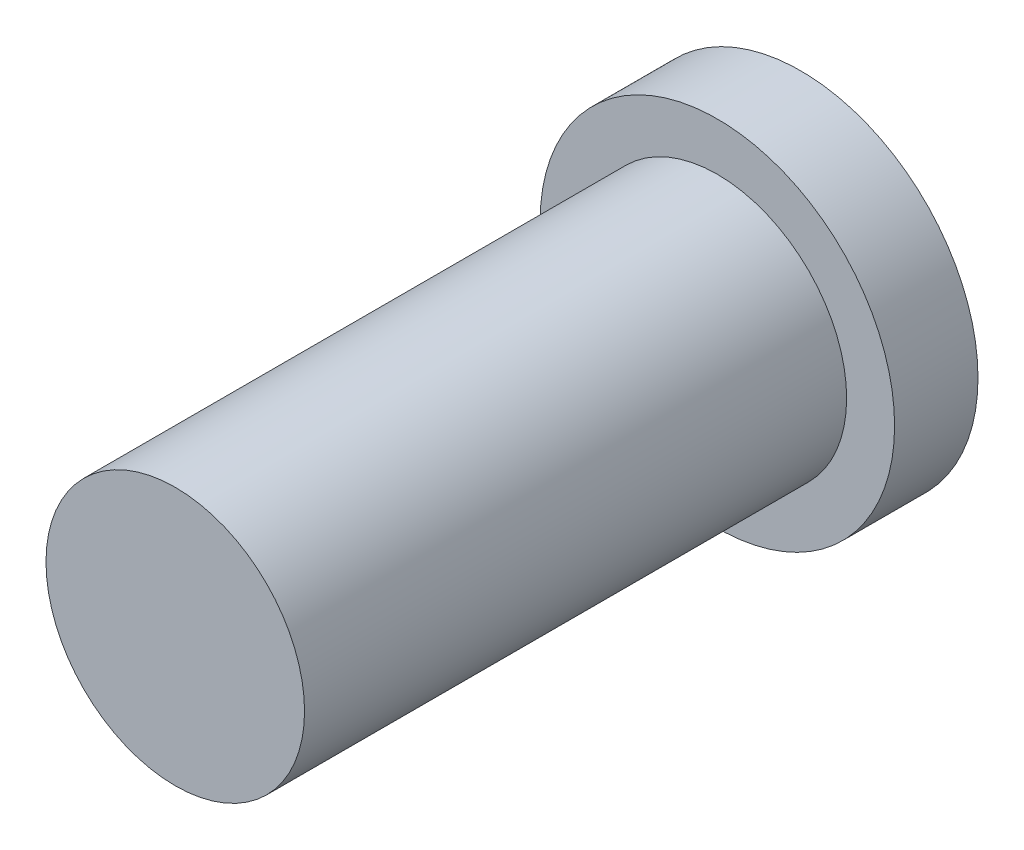
from build123d import *

# Parameters (mm, degrees)
SKETCH2_R           = 5.3975
BOSS_EXTRUDE1_DEPTH = 2.54
SKETCH3_R           = 3.937
BOSS_EXTRUDE3_DEPTH = 16.51


with BuildPart() as part:
    # Sketch2 → Boss-Extrude1 (new body)
    with BuildSketch(Plane.XY):
        Circle(SKETCH2_R)
    extrude(amount=BOSS_EXTRUDE1_DEPTH)

    # Sketch3 → Boss-Extrude3 (add)
    with BuildSketch(Plane.XY.offset(2.54)):
        Circle(SKETCH3_R)
    extrude(amount=BOSS_EXTRUDE3_DEPTH)


solid = part.part
